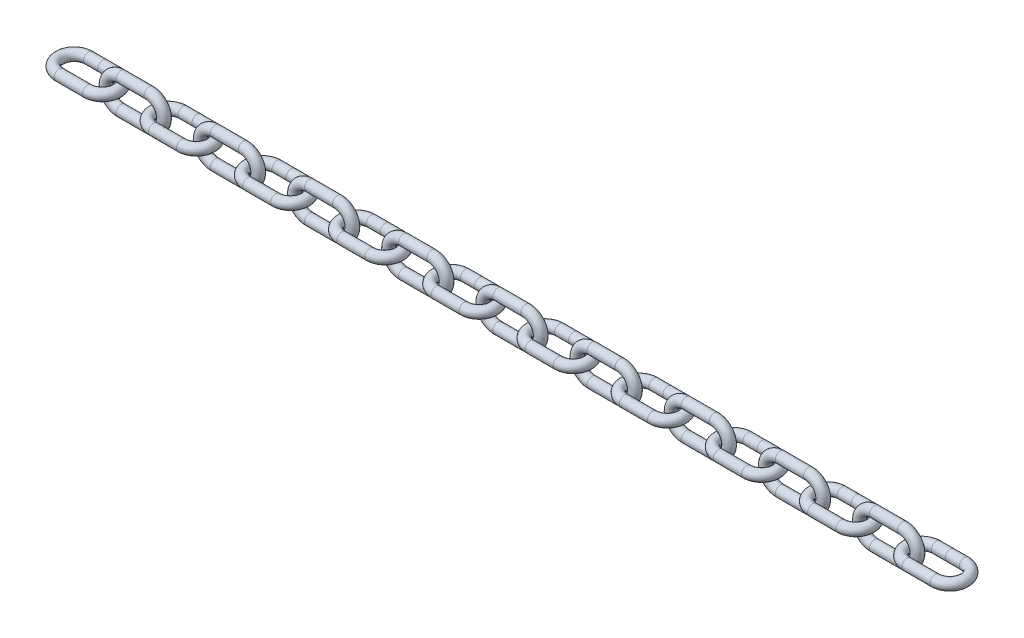
from build123d import *

# Parameters (mm, degrees)
SKETCH2_R       = 3.4925
SKETCH6_R       = 3.4925
LPATTERN1_COUNT = 9
LPATTERN1_PITCH = 62.992
LPATTERN3_COUNT = 2
LPATTERN3_PITCH = 62.992


with BuildPart() as part:
    # Sweep1: sweep along a path in Sketch1
    with BuildLine(Plane(origin=(0, 0, 0), x_dir=(1, 0, 0), z_dir=(0, 1, 0))) as sweep1_path:
        Line((9.398, 9.8425), (-9.398, 9.8425))
        ThreePointArc((-9.398, 9.8425), (-19.2405, 0), (-9.398, -9.8425))
        Line((-9.398, -9.8425), (9.398, -9.8425))
        ThreePointArc((9.398, -9.8425), (19.2405, 0), (9.398, 9.8425))
    # Sketch2 → Sweep1 (sweep)
    with BuildSketch(Plane(origin=(0, 0, 0), x_dir=(0, 0, -1), z_dir=(1, 0, 0))):
        with Locations((9.8425, 0)):
            Circle(SKETCH2_R)
    sweep(path=sweep1_path.line)


with BuildPart() as body_2:
    # Sweep2: sweep along a path in Sketch5
    with BuildLine(Plane.XY) as sweep2_path:
        Line((-22.098, 9.8425), (-40.894, 9.8425))
        ThreePointArc((-40.894, 9.8425), (-50.7365, 0), (-40.894, -9.8425))
        Line((-40.894, -9.8425), (-22.098, -9.8425))
        ThreePointArc((-22.098, -9.8425), (-12.2555, 0), (-22.098, 9.8425))
    # Sketch6 → Sweep2 (sweep)
    with BuildSketch(Plane(origin=(-22.098, 9.8425, 0), x_dir=(0, 0, 1), z_dir=(-1, 0, 0))):
        Circle(SKETCH6_R)
    sweep(path=sweep2_path.line)


with BuildPart() as lpattern1_1:
    # LPattern1: pattern copy
    add(body_2.part.moved(Location(Vector(1, 0, 0) * (1 * LPATTERN1_PITCH))))


with BuildPart() as lpattern1_2:
    # LPattern1: pattern copy
    add(body_2.part.moved(Location(Vector(1, 0, 0) * (2 * LPATTERN1_PITCH))))


with BuildPart() as lpattern1_3:
    # LPattern1: pattern copy
    add(body_2.part.moved(Location(Vector(1, 0, 0) * (3 * LPATTERN1_PITCH))))


with BuildPart() as lpattern1_4:
    # LPattern1: pattern copy
    add(body_2.part.moved(Location(Vector(1, 0, 0) * (4 * LPATTERN1_PITCH))))


with BuildPart() as lpattern1_5:
    # LPattern1: pattern copy
    add(body_2.part.moved(Location(Vector(1, 0, 0) * (5 * LPATTERN1_PITCH))))


with BuildPart() as lpattern1_6:
    # LPattern1: pattern copy
    add(body_2.part.moved(Location(Vector(1, 0, 0) * (6 * LPATTERN1_PITCH))))


with BuildPart() as lpattern1_7:
    # LPattern1: pattern copy
    add(body_2.part.moved(Location(Vector(1, 0, 0) * (7 * LPATTERN1_PITCH))))


with BuildPart() as lpattern1_8:
    # LPattern1: pattern copy
    add(body_2.part.moved(Location(Vector(1, 0, 0) * (8 * LPATTERN1_PITCH))))


with BuildPart() as lpattern1_9:
    # LPattern1: pattern copy
    add(part.part.moved(Location(Vector(1, 0, 0) * (1 * LPATTERN1_PITCH))))


with BuildPart() as lpattern1_10:
    # LPattern1: pattern copy
    add(part.part.moved(Location(Vector(1, 0, 0) * (2 * LPATTERN1_PITCH))))


with BuildPart() as lpattern1_11:
    # LPattern1: pattern copy
    add(part.part.moved(Location(Vector(1, 0, 0) * (3 * LPATTERN1_PITCH))))


with BuildPart() as lpattern1_12:
    # LPattern1: pattern copy
    add(part.part.moved(Location(Vector(1, 0, 0) * (4 * LPATTERN1_PITCH))))


with BuildPart() as lpattern1_13:
    # LPattern1: pattern copy
    add(part.part.moved(Location(Vector(1, 0, 0) * (5 * LPATTERN1_PITCH))))


with BuildPart() as lpattern1_14:
    # LPattern1: pattern copy
    add(part.part.moved(Location(Vector(1, 0, 0) * (6 * LPATTERN1_PITCH))))


with BuildPart() as lpattern1_15:
    # LPattern1: pattern copy
    add(part.part.moved(Location(Vector(1, 0, 0) * (7 * LPATTERN1_PITCH))))


with BuildPart() as lpattern1_16:
    # LPattern1: pattern copy
    add(part.part.moved(Location(Vector(1, 0, 0) * (8 * LPATTERN1_PITCH))))


with BuildPart() as lpattern3_1:
    # LPattern3: pattern copy
    add(part.part.moved(Location(Vector(-1, 0, 0) * (1 * LPATTERN3_PITCH))))


solid = Compound([part.part, body_2.part, lpattern1_1.part, lpattern1_2.part, lpattern1_3.part, lpattern1_4.part, lpattern1_5.part, lpattern1_6.part, lpattern1_7.part, lpattern1_8.part, lpattern1_9.part, lpattern1_10.part, lpattern1_11.part, lpattern1_12.part, lpattern1_13.part, lpattern1_14.part, lpattern1_15.part, lpattern1_16.part, lpattern3_1.part])
